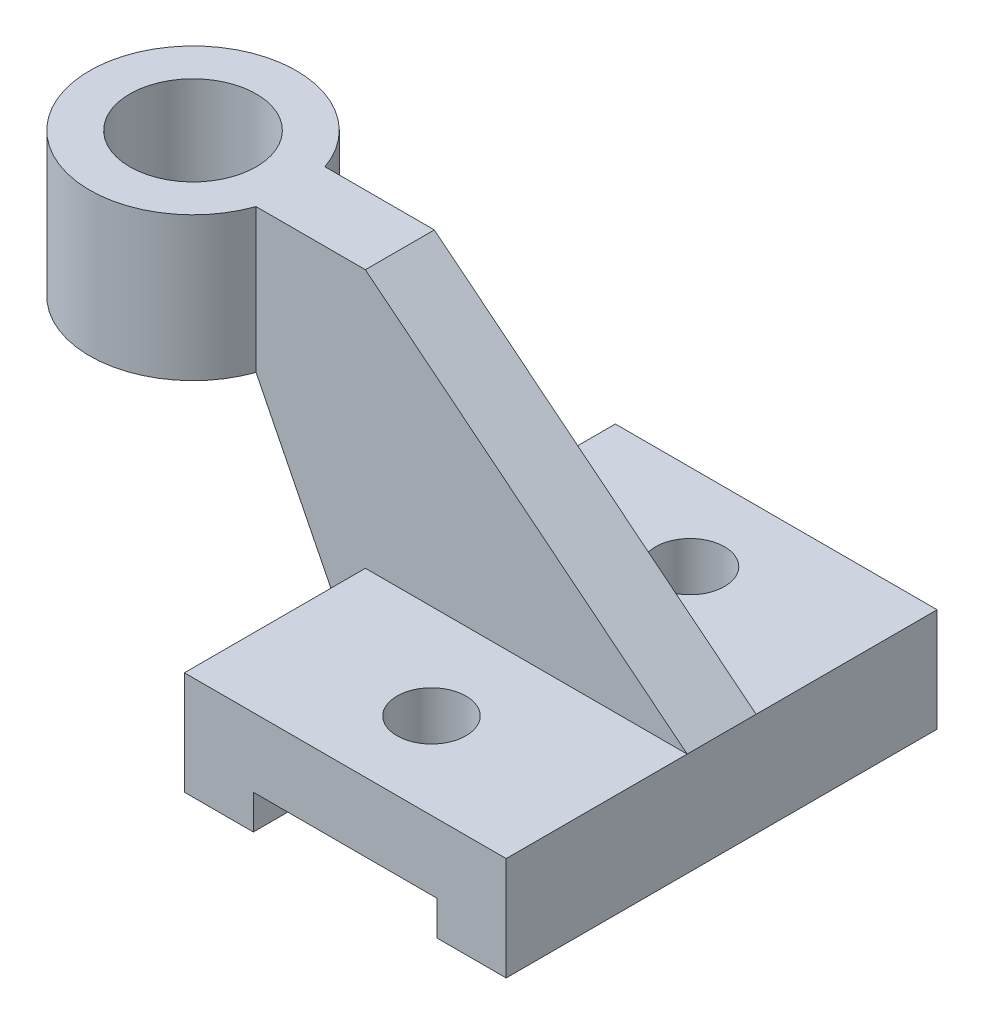
from build123d import *

# Parameters (mm, degrees)
SKETCH2_W            = 56
SKETCH2_H            = 75
BOSS_EXTRUDE1_DEPTH  = 18
SKETCH3_W            = 32
SKETCH3_H            = 75
CUT_EXTRUDE1_DEPTH   = 6
SKETCH6_R            = 6
CUT_EXTRUDE2_DEPTH   = 47
SKETCH7_W            = 56
SKETCH7_H            = 12
BOSS_EXTRUDE2_DEPTH  = 45
CUT_EXTRUDE3_DEPTH   = 45
SKETCH9_W            = 36
SKETCH9_H            = 25
BOSS_EXTRUDE5_DEPTH  = 12
SKETCH10_R           = 18
BOSS_EXTRUDE9_DEPTH  = 25
SKETCH11_R           = 11
CUT_EXTRUDE4_DEPTH   = 25
BOSS_EXTRUDE10_DEPTH = 12


with BuildPart() as part:
    # Sketch2 → Boss-Extrude1 (new body)
    with BuildSketch(Plane(origin=(0, 0, 0), x_dir=(1, 0, 0), z_dir=(0, 1, 0))):
        with Locations((28, 37.5)):
            Rectangle(SKETCH2_W, SKETCH2_H)
    extrude(amount=BOSS_EXTRUDE1_DEPTH)

    # Sketch3 → Cut-Extrude1 (cut)
    with BuildSketch(Plane.XZ):
        with Locations((28, -37.5)):
            Rectangle(SKETCH3_W, SKETCH3_H)
    extrude(amount=-CUT_EXTRUDE1_DEPTH, mode=Mode.SUBTRACT)

    # Sketch6 → Cut-Extrude2 (cut)
    with BuildSketch(Plane(origin=(0, 18, 0), x_dir=(1, 0, 0), z_dir=(0, 1, 0))):
        with Locations((28, 15)):
            Circle(SKETCH6_R)
        with Locations((28, 60)):
            Circle(SKETCH6_R)
    extrude(amount=-CUT_EXTRUDE2_DEPTH, mode=Mode.SUBTRACT)

    # Sketch7 → Boss-Extrude2 (add)
    with BuildSketch(Plane(origin=(0, 18, 0), x_dir=(1, 0, 0), z_dir=(0, 1, 0))):
        with Locations((28, 37.5)):
            Rectangle(SKETCH7_W, SKETCH7_H)
    extrude(amount=BOSS_EXTRUDE2_DEPTH)

    # Sketch8 → Cut-Extrude3 (cut)
    with BuildSketch(Plane(origin=(0, 0, -43.5), x_dir=(-1, 0, 0), z_dir=(0, 0, -1))):
        Polygon((-56, 18), (0, 63), (-56, 63), align=None)
    extrude(amount=-CUT_EXTRUDE3_DEPTH, mode=Mode.SUBTRACT)

    # Sketch9 → Boss-Extrude5 (add)
    with BuildSketch(Plane(origin=(0, 0, -43.5), x_dir=(-1, 0, 0), z_dir=(0, 0, -1))):
        with Locations((18, 50.5)):
            Rectangle(SKETCH9_W, SKETCH9_H)
    extrude(amount=-BOSS_EXTRUDE5_DEPTH)

    # Sketch10 → Boss-Extrude9 (add)
    with BuildSketch(Plane(origin=(0, 63, 0), x_dir=(1, 0, 0), z_dir=(0, 1, 0))):
        with Locations((-36, 37.5)):
            Circle(SKETCH10_R)
    extrude(amount=-BOSS_EXTRUDE9_DEPTH)

    # Sketch11 → Cut-Extrude4 (cut)
    with BuildSketch(Plane(origin=(0, 63, 0), x_dir=(1, 0, 0), z_dir=(0, 1, 0))):
        with Locations((-36, 37.5)):
            Circle(SKETCH11_R)
    extrude(amount=-CUT_EXTRUDE4_DEPTH, mode=Mode.SUBTRACT)

    # Sketch12 → Boss-Extrude10 (add)
    with BuildSketch(Plane(origin=(0, 0, -43.5), x_dir=(-1, 0, 0), z_dir=(0, 0, -1))):
        Polygon((19.029437252, 38), (0, 0), (0, 38), align=None)
    extrude(amount=-BOSS_EXTRUDE10_DEPTH)


solid = part.part
